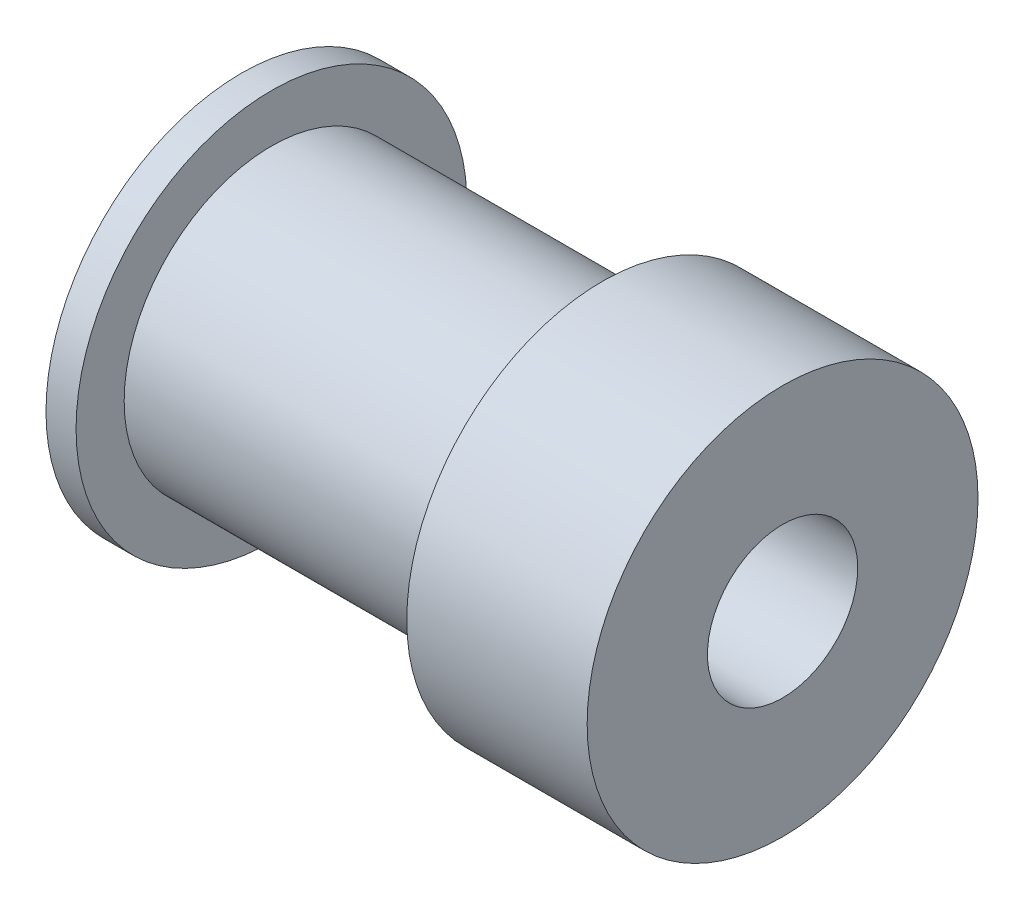
from build123d import *

# Parameters (mm, degrees)
SKETCH1_R           = 6.5
SKETCH1_R_2         = 2.5
BOSS_EXTRUDE1_DEPTH = 18
SKETCH2_R           = 6.5
SKETCH2_R_2         = 4.9
CUT_EXTRUDE1_DEPTH  = 11


with BuildPart() as part:
    # Sketch1 → Boss-Extrude1 (new body)
    with BuildSketch(Plane(origin=(0, 0, 0), x_dir=(0, 0, -1), z_dir=(1, 0, 0))):
        Circle(SKETCH1_R)
        Circle(SKETCH1_R_2, mode=Mode.SUBTRACT)
    extrude(amount=BOSS_EXTRUDE1_DEPTH)

    # Sketch2 → Cut-Extrude1 (cut)
    with BuildSketch(Plane.ZY.offset(-1)):
        Circle(SKETCH2_R)
        Circle(SKETCH2_R_2, mode=Mode.SUBTRACT)
    extrude(amount=-CUT_EXTRUDE1_DEPTH, mode=Mode.SUBTRACT)


solid = part.part
